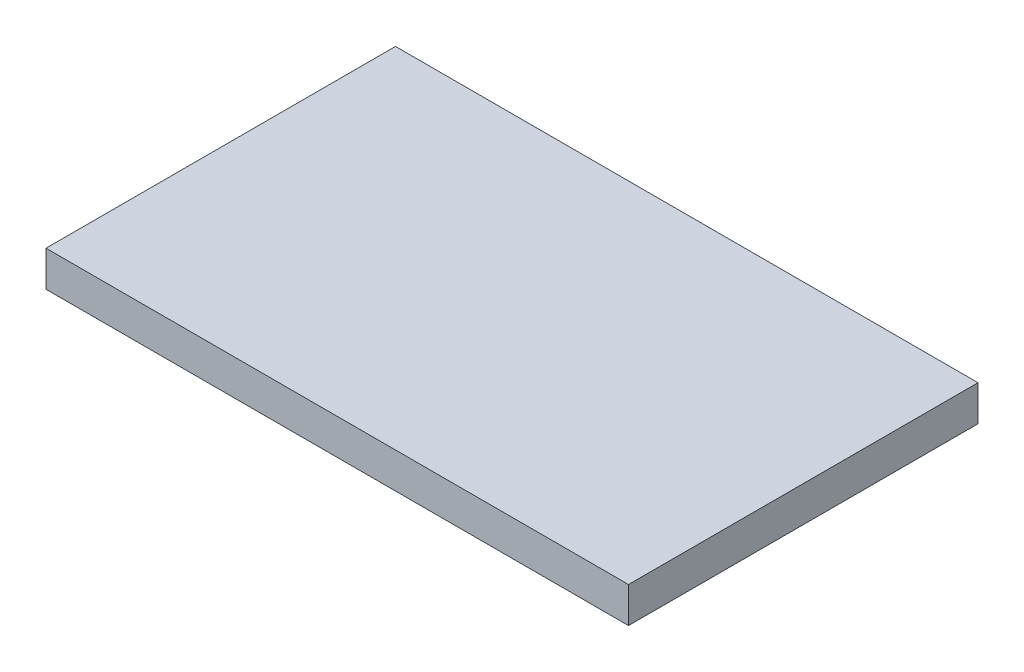
from build123d import *

# Parameters (mm, degrees)
SKETCH1_W           = 32.75
SKETCH1_H           = 19.65
BOSS_EXTRUDE1_DEPTH = 2


with BuildPart() as part:
    # Sketch1 → Boss-Extrude1 (new body)
    with BuildSketch(Plane(origin=(0, 0, 0), x_dir=(1, 0, 0), z_dir=(0, 1, 0))):
        Rectangle(SKETCH1_W, SKETCH1_H)
    extrude(amount=BOSS_EXTRUDE1_DEPTH)


solid = part.part
